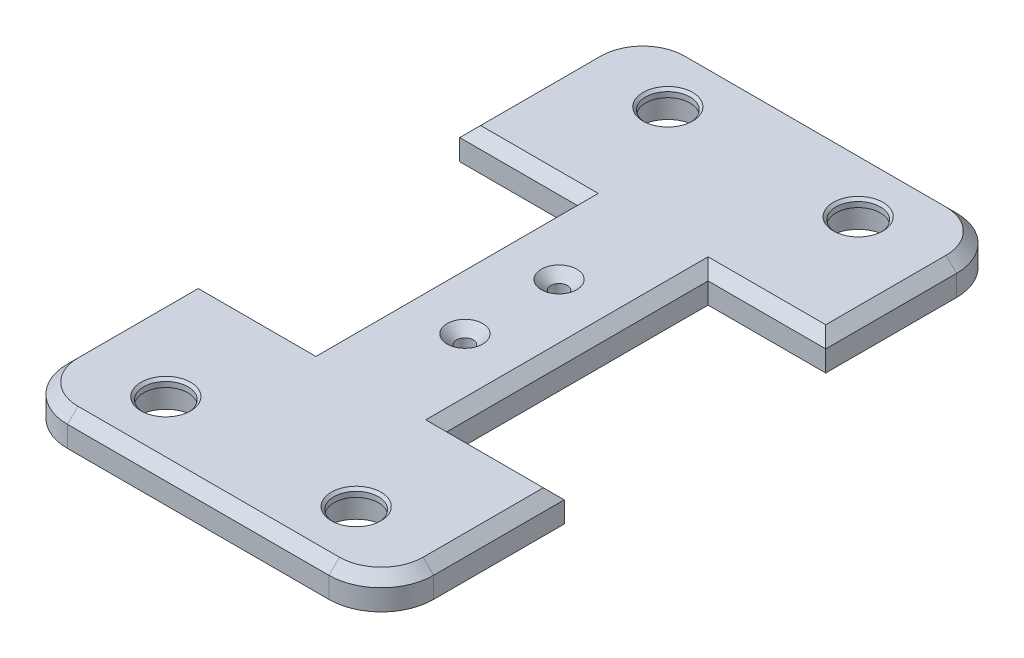
from build123d import *

# Parameters (mm, degrees)
ESQUISSE2_R             = 4.25
ESQUISSE2_R_2           = 1.6
BOSS_EXTRU_1_DEPTH      = 6
CONG_1_R                = 10
CHANFREIN1_SIZE         = 1.8
CHANFREIN2_SIZE         = 2
ESQUISSE3_R             = 5.5
ENL_V_MAT_EXTRU_1_DEPTH = 4.5
CHANFREIN3_SIZE         = 0.5


with BuildPart() as part:
    # Esquisse2 → Boss.-Extru.1 (new body)
    with BuildSketch(Plane(origin=(0, 0, 0), x_dir=(1, 0, 0), z_dir=(0, 1, 0))):
        Polygon((-12.5, -25), (-12.5, 25), (-35, 25), (-35, 60), (35, 60), (35, 25), (12.5, 25), (12.5, -25), (35, -25), (35, -60), (-35, -60), (-35, -25), align=None)
        with Locations((-18.2, 48)):
            Circle(ESQUISSE2_R, mode=Mode.SUBTRACT)
        with Locations((18.2, 48)):
            Circle(ESQUISSE2_R, mode=Mode.SUBTRACT)
        with Locations((18.2, -48)):
            Circle(ESQUISSE2_R, mode=Mode.SUBTRACT)
        with Locations((-18.2, -48)):
            Circle(ESQUISSE2_R, mode=Mode.SUBTRACT)
        with Locations((0, 9)):
            Circle(ESQUISSE2_R_2, mode=Mode.SUBTRACT)
        with Locations((0, -9)):
            Circle(ESQUISSE2_R_2, mode=Mode.SUBTRACT)
    extrude(amount=BOSS_EXTRU_1_DEPTH)

    # Congé1
    cong_1_edges = [part.edges().sort_by_distance(p)[0] for p in [
        (-35, 3, -60),
        (35, 3, -60),
        (35, 3, 60),
        (-35, 3, 60),
    ]]
    fillet(cong_1_edges, radius=CONG_1_R)

    # Chanfrein1
    chanfrein1_edges = [part.edges().sort_by_distance(p)[0] for p in [
        (-1.6, 6, -9),
        (-1.6, 6, 9),
    ]]
    chamfer(chanfrein1_edges, length=CHANFREIN1_SIZE)

    # Chanfrein2
    chanfrein2_edges = [part.edges().sort_by_distance(p)[0] for p in [
        (-23.75, 6, 25),
        (-35, 6, 37.5),
        (23.75, 6, 25),
        (12.5, 6, 0),
        (23.75, 6, -25),
        (35, 6, -37.5),
        (-23.75, 6, -25),
        (0, 6, 60),
        (35, 6, 37.5),
        (0, 6, -60),
        (-35, 6, -37.5),
        (-32.071067812, 6, -57.071067812),
        (32.071067812, 6, -57.071067812),
        (32.071067812, 6, 57.071067812),
        (-32.071067812, 6, 57.071067812),
        (-12.5, 6, 0),
    ]]
    chamfer(chanfrein2_edges, length=CHANFREIN2_SIZE)

    # Esquisse3 → Enlèv. mat.-Extru.1 (cut)
    with BuildSketch(Plane.XZ):
        with Locations((-18.2, 48)):
            Circle(ESQUISSE3_R)
        with Locations((18.2, 48)):
            Circle(ESQUISSE3_R)
        with Locations((18.2, -48)):
            Circle(ESQUISSE3_R)
        with Locations((-18.2, -48)):
            Circle(ESQUISSE3_R)
    extrude(amount=-ENL_V_MAT_EXTRU_1_DEPTH, mode=Mode.SUBTRACT)

    # Chanfrein3
    chanfrein3_edges = [part.edges().sort_by_distance(p)[0] for p in [
        (-22.45, 6, -48),
        (13.95, 6, -48),
        (13.95, 6, 48),
        (-22.45, 6, 48),
    ]]
    chamfer(chanfrein3_edges, length=CHANFREIN3_SIZE)


solid = part.part
